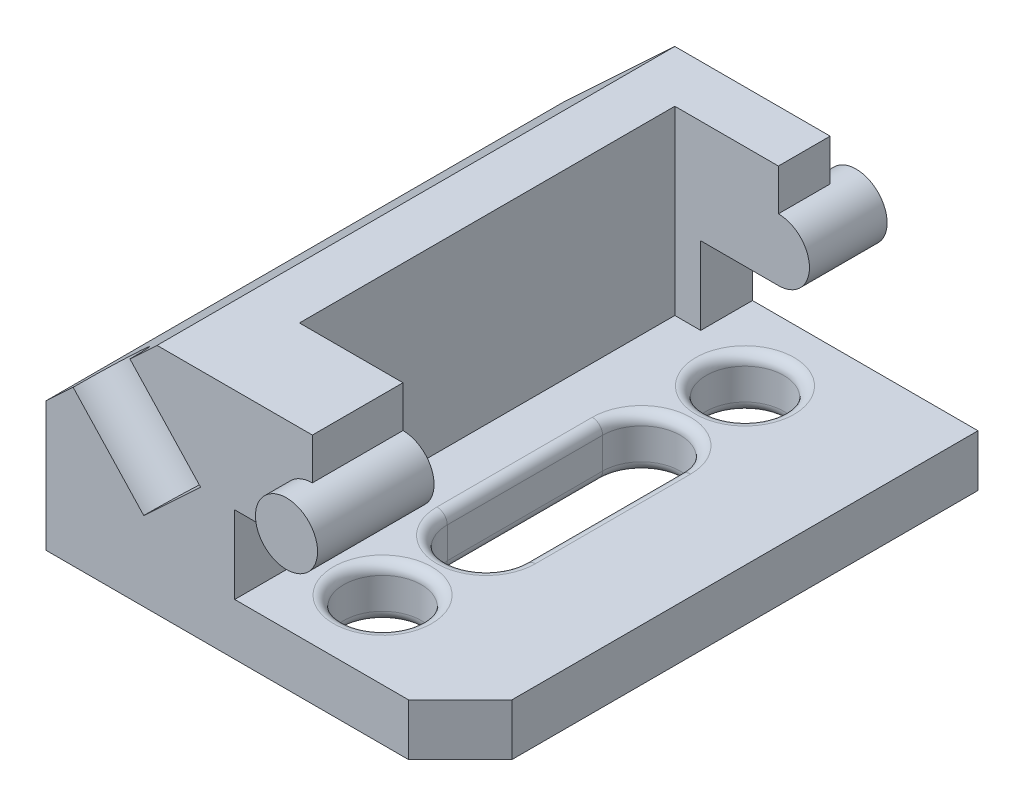
from build123d import *

# Parameters (mm, degrees)
DODANIE_WYCI_GNI_CIE1_DEPTH      = 100
SFAZOWANIE1_SIZE                 = 10
SZKIC3_R                         = 6
DODANIE_WYCI_GNI_CIE2_DEPTH      = 5
DODANIE_WYCI_GNI_CIE2_DEPTH_BACK = 105
SZKIC4_W                         = 26
SZKIC4_H                         = 72.5
WYTNIJ_WYCI_GNI_CIE1_DEPTH       = 35
SZKIC5_R                         = 7.5
WYTNIJ_WYCI_GNI_CIE3_DEPTH       = 11
ZAOKR_GLENIE2_R                  = 2
SZKIC6_R                         = 7.5
WYTNIJ_WYCI_GNI_CIE5_DEPTH       = 20


with BuildPart() as part:
    # Szkic2 → Dodanie-wyciągnięcie1 (new body)
    with BuildSketch(Plane.XY):
        with BuildLine():
            Line((0, 0), (80, 0))
            Line((80, 0), (80, 10))
            Line((80, 10), (36.4473742, 10))
            Line((36.4473742, 10), (36.4473742, 25))
            Line((36.4473742, 25), (51.4473742, 25))
            ThreePointArc((51.4473742, 25), (57.4473742, 31), (51.4473742, 37))
            Line((51.4473742, 37), (51.4473742, 45))
            Line((51.4473742, 45), (21.4473742, 45))
            Line((21.4473742, 45), (0, 25))
            Line((0, 25), (0, 0))
        make_face()
    extrude(amount=DODANIE_WYCI_GNI_CIE1_DEPTH)

    # Sfazowanie1
    sfazowanie1_edges = [part.edges().sort_by_distance(p)[0] for p in [
        (80, 5, 100),
    ]]
    chamfer(sfazowanie1_edges, length=SFAZOWANIE1_SIZE)

    # Szkic3 → Dodanie-wyciągnięcie2 (add, two sides)
    with BuildSketch(Plane.XY.offset(100)) as dodanie_wyci_gni_cie2_sk:
        with Locations((51.4473742, 31)):
            Circle(SZKIC3_R)
    extrude(amount=DODANIE_WYCI_GNI_CIE2_DEPTH)
    extrude(dodanie_wyci_gni_cie2_sk.sketch, amount=-DODANIE_WYCI_GNI_CIE2_DEPTH_BACK)

    # Szkic4 → Wytnij-wyciągnięcie1 (cut)
    with BuildSketch(Plane(origin=(0, 45, 0), x_dir=(1, 0, 0), z_dir=(0, 1, 0))):
        with Locations((44.4473742, -46.25)):
            Rectangle(SZKIC4_W, SZKIC4_H)
    extrude(amount=-WYTNIJ_WYCI_GNI_CIE1_DEPTH, mode=Mode.SUBTRACT)

    # Szkic5 → Wytnij-wyciągnięcie3 (cut, through all)
    with BuildSketch(Plane(origin=(0, 10, 0), x_dir=(1, 0, 0), z_dir=(0, 1, 0))):
        with Locations((50, -15)):
            Circle(SZKIC5_R)
        with Locations((50, -85)):
            Circle(SZKIC5_R)
        with BuildLine():
            Line((42.5, -35), (42.5, -65))
            ThreePointArc((42.5, -65), (50, -72.5), (57.5, -65))
            Line((57.5, -65), (57.5, -35))
            ThreePointArc((57.5, -35), (50, -27.5), (42.5, -35))
        make_face()
    extrude(amount=-WYTNIJ_WYCI_GNI_CIE3_DEPTH, mode=Mode.SUBTRACT)

    # Zaokrąglenie2
    zaokr_glenie2_edges = [part.edges().sort_by_distance(p)[0] for p in [
        (42.5, 0, 15),
        (42.5, 10, 15),
        (42.5, 0, 85),
        (42.5, 10, 85),
        (50, 0, 27.5),
        (57.5, 0, 50),
        (50, 0, 72.5),
        (42.5, 0, 50),
        (50, 10, 27.5),
        (42.5, 10, 50),
        (50, 10, 72.5),
        (57.5, 10, 50),
    ]]
    fillet(zaokr_glenie2_edges, radius=ZAOKR_GLENIE2_R)

    # Szkic6 → Wytnij-wyciągnięcie5 (cut)
    with BuildSketch(Plane(origin=(-12.469550628, 13.371955922, 0), x_dir=(0.731353702, 0.68199836, 0), z_dir=(-0.68199836, 0.731353702, 0))):
        with Locations((31.712750858, -100)):
            Circle(SZKIC6_R)
    extrude(amount=-WYTNIJ_WYCI_GNI_CIE5_DEPTH, mode=Mode.SUBTRACT)


solid = part.part
